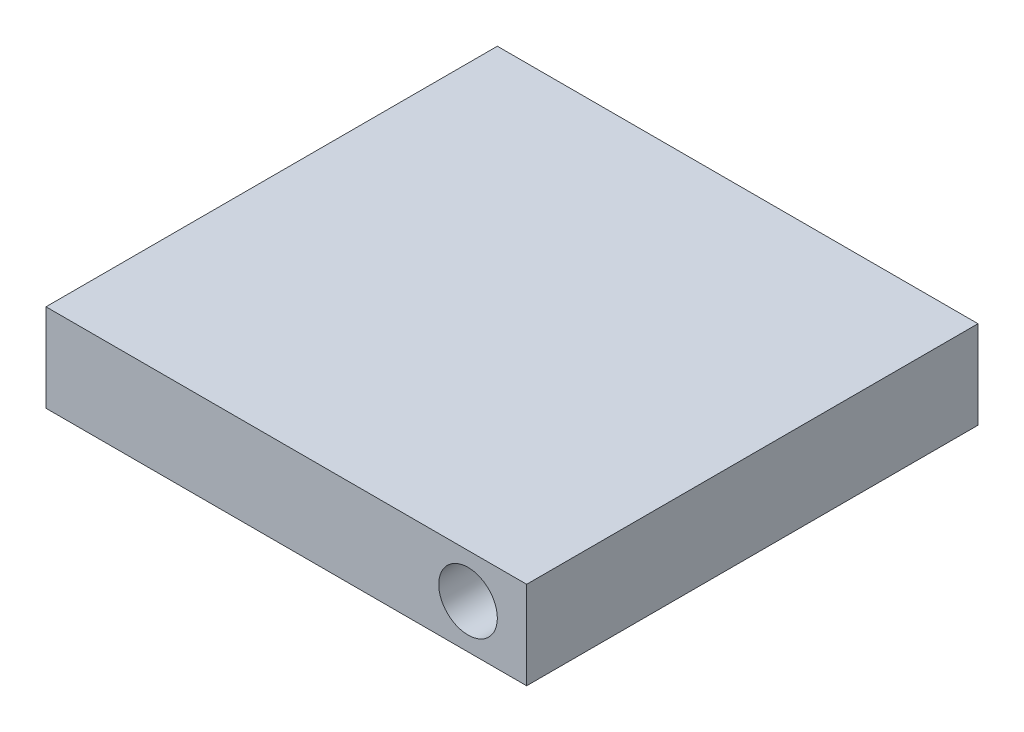
from build123d import *

# Parameters (mm, degrees)
CROQUIS1_W               = 2
CROQUIS1_H               = 2
SALIENTE_EXTRUIR1_DEPTH  = 0.2
CROQUIS2_W               = 2.6
CROQUIS2_H               = 2.6
SALIENTE_EXTRUIR2_DEPTH  = 0.2
CROQUIS3_W               = 3.2
CROQUIS3_H               = 3.2
SALIENTE_EXTRUIR3_DEPTH  = 0.2
CROQUIS4_W               = 3.8
CROQUIS4_H               = 3.8
SALIENTE_EXTRUIR4_DEPTH  = 0.2
CROQUIS5_W               = 4.4
CROQUIS5_H               = 4.4
SALIENTE_EXTRUIR5_DEPTH  = 0.2
CROQUIS6_W               = 5
CROQUIS6_H               = 5
SALIENTE_EXTRUIR6_DEPTH  = 0.2
CROQUIS7_W               = 5.6
CROQUIS7_H               = 5.6
SALIENTE_EXTRUIR7_DEPTH  = 0.2
CROQUIS8_W               = 6.2
CROQUIS8_H               = 6.2
SALIENTE_EXTRUIR8_DEPTH  = 0.2
CROQUIS9_W               = 6.8
CROQUIS9_H               = 6.8
SALIENTE_EXTRUIR9_DEPTH  = 0.2
CROQUIS10_W              = 7.4
CROQUIS10_H              = 7.4
SALIENTE_EXTRUIR10_DEPTH = 0.2
CROQUIS11_W              = 16.4
CROQUIS11_H              = 15.4
SALIENTE_EXTRUIR11_DEPTH = 3
CROQUIS12_R              = 1
CORTAR_EXTRUIR1_DEPTH    = 16.4


with BuildPart() as part:
    # Croquis1 → Saliente-Extruir1 (new body)
    with BuildSketch(Plane(origin=(0, 0, 0), x_dir=(1, 0, 0), z_dir=(0, 1, 0))):
        with Locations((1, -1)):
            Rectangle(CROQUIS1_W, CROQUIS1_H)
    extrude(amount=SALIENTE_EXTRUIR1_DEPTH)

    # Croquis2 → Saliente-Extruir2 (add)
    with BuildSketch(Plane(origin=(0, 0.2, 0), x_dir=(1, 0, 0), z_dir=(0, 1, 0))):
        with Locations((1, -1)):
            Rectangle(CROQUIS2_W, CROQUIS2_H)
    extrude(amount=SALIENTE_EXTRUIR2_DEPTH)

    # Croquis3 → Saliente-Extruir3 (add)
    with BuildSketch(Plane(origin=(0, 0.4, 0), x_dir=(1, 0, 0), z_dir=(0, 1, 0))):
        with Locations((1, -1)):
            Rectangle(CROQUIS3_W, CROQUIS3_H)
    extrude(amount=SALIENTE_EXTRUIR3_DEPTH)

    # Croquis4 → Saliente-Extruir4 (add)
    with BuildSketch(Plane(origin=(0, 0.6, 0), x_dir=(1, 0, 0), z_dir=(0, 1, 0))):
        with Locations((1, -1)):
            Rectangle(CROQUIS4_W, CROQUIS4_H)
    extrude(amount=SALIENTE_EXTRUIR4_DEPTH)

    # Croquis5 → Saliente-Extruir5 (add)
    with BuildSketch(Plane(origin=(0, 0.8, 0), x_dir=(1, 0, 0), z_dir=(0, 1, 0))):
        with Locations((1, -1)):
            Rectangle(CROQUIS5_W, CROQUIS5_H)
    extrude(amount=SALIENTE_EXTRUIR5_DEPTH)

    # Croquis6 → Saliente-Extruir6 (add)
    with BuildSketch(Plane(origin=(0, 1, 0), x_dir=(1, 0, 0), z_dir=(0, 1, 0))):
        with Locations((1, -1)):
            Rectangle(CROQUIS6_W, CROQUIS6_H)
    extrude(amount=SALIENTE_EXTRUIR6_DEPTH)

    # Croquis7 → Saliente-Extruir7 (add)
    with BuildSketch(Plane(origin=(0, 1.2, 0), x_dir=(1, 0, 0), z_dir=(0, 1, 0))):
        with Locations((1, -1)):
            Rectangle(CROQUIS7_W, CROQUIS7_H)
    extrude(amount=SALIENTE_EXTRUIR7_DEPTH)

    # Croquis8 → Saliente-Extruir8 (add)
    with BuildSketch(Plane(origin=(0, 1.4, 0), x_dir=(1, 0, 0), z_dir=(0, 1, 0))):
        with Locations((1, -1)):
            Rectangle(CROQUIS8_W, CROQUIS8_H)
    extrude(amount=SALIENTE_EXTRUIR8_DEPTH)

    # Croquis9 → Saliente-Extruir9 (add)
    with BuildSketch(Plane(origin=(0, 1.6, 0), x_dir=(1, 0, 0), z_dir=(0, 1, 0))):
        with Locations((1, -1)):
            Rectangle(CROQUIS9_W, CROQUIS9_H)
    extrude(amount=SALIENTE_EXTRUIR9_DEPTH)

    # Croquis10 → Saliente-Extruir10 (add)
    with BuildSketch(Plane(origin=(0, 1.8, 0), x_dir=(1, 0, 0), z_dir=(0, 1, 0))):
        with Locations((1, -1)):
            Rectangle(CROQUIS10_W, CROQUIS10_H)
    extrude(amount=SALIENTE_EXTRUIR10_DEPTH)

    # Croquis11 → Saliente-Extruir11 (add)
    with BuildSketch(Plane(origin=(0, 2, 0), x_dir=(1, 0, 0), z_dir=(0, 1, 0))):
        with Locations((1.5, -1)):
            Rectangle(CROQUIS11_W, CROQUIS11_H)
    extrude(amount=SALIENTE_EXTRUIR11_DEPTH)

    # Croquis12 → Cortar-Extruir1 (cut, through all)
    with BuildSketch(Plane.XY.offset(8.7)):
        with Locations((7.7, 3.5)):
            Circle(CROQUIS12_R)
    extrude(amount=-CORTAR_EXTRUIR1_DEPTH, mode=Mode.SUBTRACT)


solid = part.part
